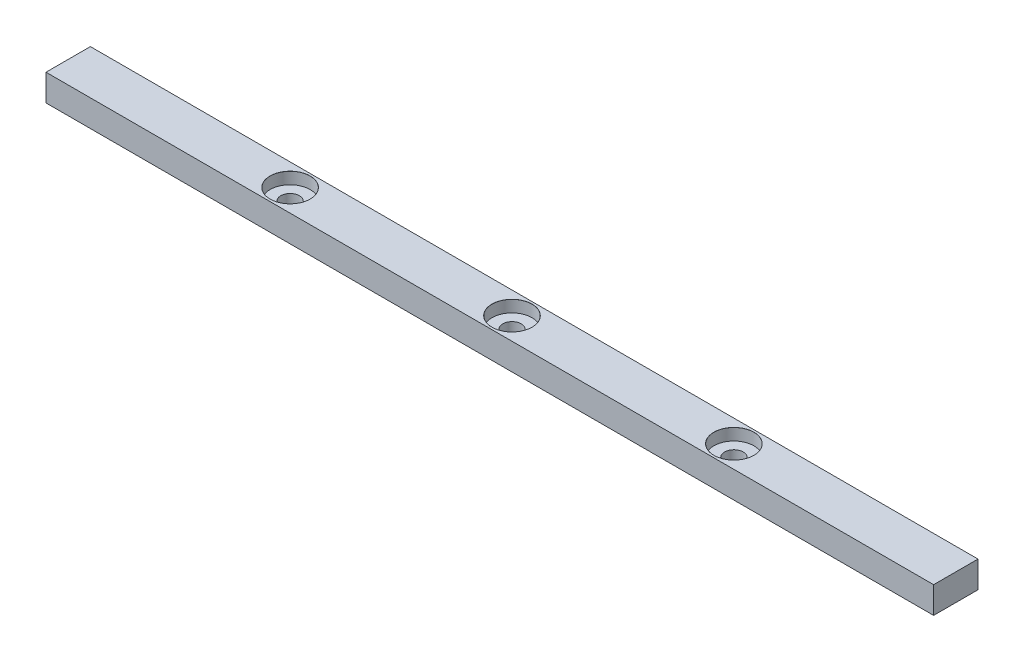
from build123d import *

# Parameters (mm, degrees)
SKETCH1_W                              = 400
SKETCH1_H                              = 20
BOSS_EXTRUDE1_DEPTH                    = 12
CBORE_FOR_M8_HEX_HEAD_BOLT1_AT_2_COUNT = 2
CBORE_FOR_M8_HEX_HEAD_BOLT1_AT_2_PITCH = 100
CBORE_FOR_M8_HEX_HEAD_BOLT1_AT_3_COUNT = 2
CBORE_FOR_M8_HEX_HEAD_BOLT1_AT_3_PITCH = 100


with BuildPart() as part:
    # Sketch1 → Boss-Extrude1 (new body)
    with BuildSketch(Plane(origin=(0, 0, 0), x_dir=(1, 0, 0), z_dir=(0, 1, 0))):
        Rectangle(SKETCH1_W, SKETCH1_H)
    extrude(amount=BOSS_EXTRUDE1_DEPTH)

    # Sketch5 → CBORE for M8 Hex Head Bolt1 (revolve, cut)
    with BuildSketch(Plane(origin=(0, 12, 0), x_dir=(0, 0, 1), z_dir=(1, 0, 0))):
        Polygon((0, 0), (0, 12), (4.2, 12), (4.2, 5.3), (9.0055, 5.3), (9.0055, 0.025), (9.0305, 0), align=None)
    cbore_for_m8_hex_head_bolt1 = revolve(axis=Axis((0, 18.35, 0), (0, -1, 0)), mode=Mode.SUBTRACT)

    # CBORE for M8 Hex Head Bolt1 at 2: CBORE for M8 Hex Head Bolt1 ×2
    with Locations(*[(i * CBORE_FOR_M8_HEX_HEAD_BOLT1_AT_2_PITCH, 0, 0) for i in range(1, CBORE_FOR_M8_HEX_HEAD_BOLT1_AT_2_COUNT)]):
        add(cbore_for_m8_hex_head_bolt1, mode=Mode.SUBTRACT)

    # CBORE for M8 Hex Head Bolt1 at 3: CBORE for M8 Hex Head Bolt1 ×2
    with Locations(*[(-i * CBORE_FOR_M8_HEX_HEAD_BOLT1_AT_3_PITCH, 0, 0) for i in range(1, CBORE_FOR_M8_HEX_HEAD_BOLT1_AT_3_COUNT)]):
        add(cbore_for_m8_hex_head_bolt1, mode=Mode.SUBTRACT)


solid = part.part
